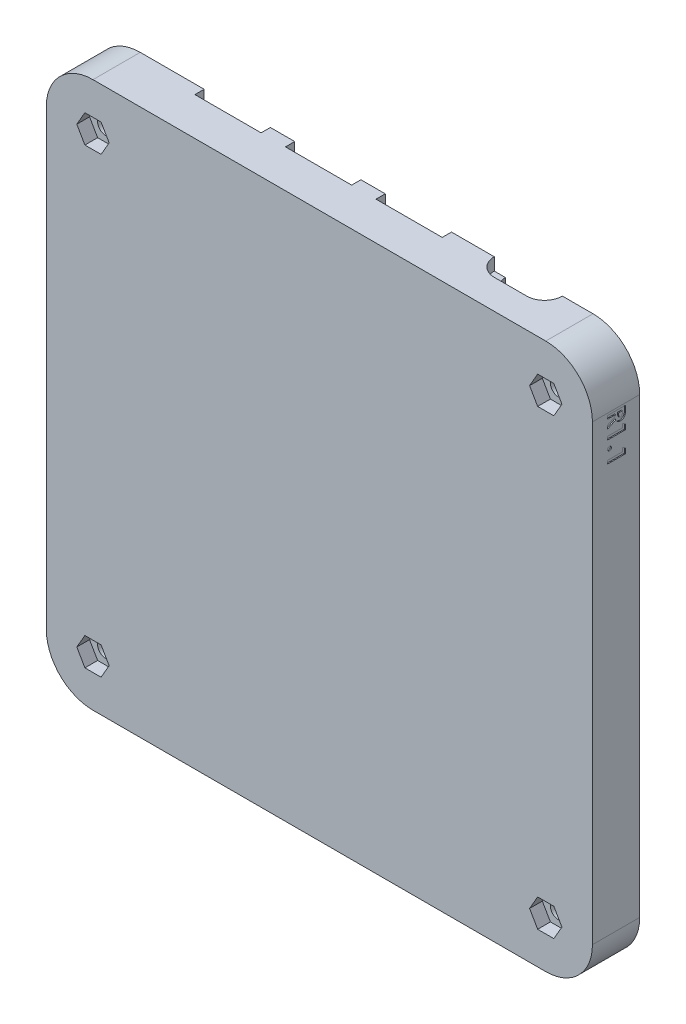
from build123d import *

# Parameters (mm, degrees)
SKETCH1_R             = 3.6
SKETCH1_R_2           = 1.6
BOSS_EXTRUDE1_DEPTH   = 3
BOSS_EXTRUDE1_2_DEPTH = 3
BOSS_EXTRUDE1_3_DEPTH = 3
BOSS_EXTRUDE1_4_DEPTH = 3
BOSS_EXTRUDE2_DEPTH   = 6.28
SKETCH3_R             = 1.6
BOSS_EXTRUDE3_DEPTH   = 3
CUT_EXTRUDE1_REACH    = 109.228
SKETCH5_W             = 13
SKETCH5_H             = 11.3
CUT_EXTRUDE2_START    = -2.436
CUT_EXTRUDE2_DEPTH    = 2.436
CUT_EXTRUDE3_REACH    = 109.228
SKETCH8_W             = 7.93
SKETCH8_H             = 14.6
CUT_EXTRUDE4_REACH    = 109.228
SKETCH9_W             = 10.28
SKETCH9_H             = 1.68
CHAMFER1_SIZE         = 1
CHAMFER1_SIZE2        = 3.732050808
CUT_EXTRUDE5_DEPTH    = 2.5
CUT_EXTRUDE6_DEPTH    = 0.2


with BuildPart() as part:
    # Sketch1 → Boss-Extrude1 (new body)
    with BuildSketch(Plane.XY):
        with Locations((-20.32, -20.32)):
            Circle(SKETCH1_R)
        with Locations((-20.32, -20.32)):
            Circle(SKETCH1_R_2, mode=Mode.SUBTRACT)
    extrude(amount=BOSS_EXTRUDE1_DEPTH)



with BuildPart() as body_2:
    # Sketch1 → Boss-Extrude1 2 (new body)
    with BuildSketch(Plane.XY):
        with Locations((-20.32, -109.22)):
            Circle(SKETCH1_R)
        with Locations((-20.32, -109.22)):
            Circle(SKETCH1_R_2, mode=Mode.SUBTRACT)
    extrude(amount=BOSS_EXTRUDE1_2_DEPTH)


with BuildPart() as body_3:
    # Sketch1 → Boss-Extrude1 3 (new body)
    with BuildSketch(Plane.XY):
        with Locations((-109.22, -109.22)):
            Circle(SKETCH1_R)
        with Locations((-109.22, -109.22)):
            Circle(SKETCH1_R_2, mode=Mode.SUBTRACT)
    extrude(amount=BOSS_EXTRUDE1_3_DEPTH)


with BuildPart() as body_4:
    # Sketch1 → Boss-Extrude1 4 (new body)
    with BuildSketch(Plane.XY):
        with Locations((-109.22, -20.32)):
            Circle(SKETCH1_R)
        with Locations((-109.22, -20.32)):
            Circle(SKETCH1_R_2, mode=Mode.SUBTRACT)
    extrude(amount=BOSS_EXTRUDE1_4_DEPTH)


with BuildPart() as body_5:
    # Sketch2 → Boss-Extrude2 (new body)
    with BuildSketch(Plane.XY.offset(3)):
        with BuildLine():
            Line((-20.32, -11.156), (-109.22, -11.156))
            ThreePointArc((-109.22, -11.156), (-115.699926543, -13.840073457), (-118.384, -20.32))
            Line((-118.384, -20.32), (-118.384, -109.22))
            ThreePointArc((-118.384, -109.22), (-115.699926543, -115.699926543), (-109.22, -118.384))
            Line((-109.22, -118.384), (-20.32, -118.384))
            ThreePointArc((-20.32, -118.384), (-13.840073457, -115.699926543), (-11.156, -109.22))
            Line((-11.156, -109.22), (-11.156, -20.32))
            ThreePointArc((-11.156, -20.32), (-13.840073457, -13.840073457), (-20.32, -11.156))
        make_face()
        with BuildLine():
            Line((-109.22, -114.4), (-20.32, -114.4))
            ThreePointArc((-20.32, -114.4), (-16.657186873, -112.882813127), (-15.14, -109.22))
            Line((-15.14, -109.22), (-15.14, -20.32))
            ThreePointArc((-15.14, -20.32), (-16.657186873, -16.657186873), (-20.32, -15.14))
            Line((-20.32, -15.14), (-109.22, -15.14))
            ThreePointArc((-109.22, -15.14), (-112.882813127, -16.657186873), (-114.4, -20.32))
            Line((-114.4, -20.32), (-114.4, -109.22))
            ThreePointArc((-114.4, -109.22), (-112.882813127, -112.882813127), (-109.22, -114.4))
        make_face(mode=Mode.SUBTRACT)
    extrude(amount=-BOSS_EXTRUDE2_DEPTH)


with BuildPart() as part_1:
    add(part.part)

    add(body_2.part)  # Boss-Extrude3 merges body 2

    add(body_3.part)  # Boss-Extrude3 merges body 3

    add(body_4.part)  # Boss-Extrude3 merges body 4

    add(body_5.part)  # Boss-Extrude3 merges body 5
    # Sketch3 → Boss-Extrude3 (add)
    with BuildSketch(Plane.XY.offset(3)):
        with BuildLine():
            Line((-11.156, -109.22), (-11.156, -20.32))
            ThreePointArc((-11.156, -20.32), (-13.840073457, -13.840073457), (-20.32, -11.156))
            Line((-20.32, -11.156), (-109.22, -11.156))
            ThreePointArc((-109.22, -11.156), (-115.699926543, -13.840073457), (-118.384, -20.32))
            Line((-118.384, -20.32), (-118.384, -109.22))
            ThreePointArc((-118.384, -109.22), (-115.699926543, -115.699926543), (-109.22, -118.384))
            Line((-109.22, -118.384), (-20.32, -118.384))
            ThreePointArc((-20.32, -118.384), (-13.840073457, -115.699926543), (-11.156, -109.22))
        make_face()
        with Locations((-109.22, -109.22)):
            Circle(SKETCH3_R, mode=Mode.SUBTRACT)
        with Locations((-20.32, -109.22)):
            Circle(SKETCH3_R, mode=Mode.SUBTRACT)
        with Locations((-20.32, -20.32)):
            Circle(SKETCH3_R, mode=Mode.SUBTRACT)
        with Locations((-109.22, -20.32)):
            Circle(SKETCH3_R, mode=Mode.SUBTRACT)
    extrude(amount=BOSS_EXTRUDE3_DEPTH)

    # Sketch5 → Cut-Extrude1 (cut, up to next)
    with BuildSketch(Plane(origin=(0, -11.156, 0), x_dir=(1, 0, 0), z_dir=(0, 1, 0)), mode=Mode.PRIVATE) as cut_extrude1_sk1:
        with Locations((-90.17, 7.111)):
            Rectangle(SKETCH5_W, SKETCH5_H)
    cut_extrude1_tool1 = extrude(cut_extrude1_sk1.sketch, amount=-CUT_EXTRUDE1_REACH, mode=Mode.PRIVATE) & part_1.part
    add(cut_extrude1_tool1.solids().sort_by_distance((-90.17, -11.156, -7.111))[0], mode=Mode.SUBTRACT)
    # Sketch5 → Cut-Extrude1 (cut, up to next)
    with BuildSketch(Plane(origin=(0, -11.156, 0), x_dir=(1, 0, 0), z_dir=(0, 1, 0)), mode=Mode.PRIVATE) as cut_extrude1_sk2:
        with Locations((-72.39, 7.111)):
            Rectangle(SKETCH5_W, SKETCH5_H)
    cut_extrude1_tool2 = extrude(cut_extrude1_sk2.sketch, amount=-CUT_EXTRUDE1_REACH, mode=Mode.PRIVATE) & part_1.part
    add(cut_extrude1_tool2.solids().sort_by_distance((-72.39, -11.156, -7.111))[0], mode=Mode.SUBTRACT)
    # Sketch5 → Cut-Extrude1 (cut, up to next)
    with BuildSketch(Plane(origin=(0, -11.156, 0), x_dir=(1, 0, 0), z_dir=(0, 1, 0)), mode=Mode.PRIVATE) as cut_extrude1_sk3:
        with Locations((-54.61, 7.111)):
            Rectangle(SKETCH5_W, SKETCH5_H)
    cut_extrude1_tool3 = extrude(cut_extrude1_sk3.sketch, amount=-CUT_EXTRUDE1_REACH, mode=Mode.PRIVATE) & part_1.part
    add(cut_extrude1_tool3.solids().sort_by_distance((-54.61, -11.156, -7.111))[0], mode=Mode.SUBTRACT)
    # Sketch5 → Cut-Extrude1 (cut, up to next)
    with BuildSketch(Plane(origin=(0, -11.156, 0), x_dir=(1, 0, 0), z_dir=(0, 1, 0)), mode=Mode.PRIVATE) as cut_extrude1_sk4:
        with BuildLine():
            Line((-29.830000144, 1.7), (-33.265, 1.7))
            Line((-33.265, 1.7), (-33.275, 1.7))
            Line((-33.275, 1.7), (-36.210000373, 1.7))
            ThreePointArc((-36.210000373, 1.7), (-37.115096812, 2.074903452), (-37.49, 2.98))
            Line((-37.49, 2.98), (-37.49, 3.579998881))
            ThreePointArc((-37.49, 3.579998881), (-37.115098465, 4.485094895), (-36.210003931, 4.86))
            Line((-36.210003931, 4.86), (-29.830005587, 4.86))
            ThreePointArc((-29.830005587, 4.86), (-28.924905628, 4.485098988), (-28.55, 3.580000941))
            Line((-28.55, 3.580000941), (-28.55, 2.97999964))
            ThreePointArc((-28.55, 2.97999964), (-28.924903498, 2.074903142), (-29.830000144, 1.7))
        make_face()
    cut_extrude1_tool4 = extrude(cut_extrude1_sk4.sketch, amount=-CUT_EXTRUDE1_REACH, mode=Mode.PRIVATE) & part_1.part
    add(cut_extrude1_tool4.solids().sort_by_distance((-33.02, -11.156, -3.28))[0], mode=Mode.SUBTRACT)

    # Sketch7 → Cut-Extrude2 (cut)
    with BuildSketch(Plane(origin=(0, -11.156, 0), x_dir=(1, 0, 0), z_dir=(0, 1, 0)).offset(CUT_EXTRUDE2_START)):
        with BuildLine():
            Line((-36.21, 6.78), (-29.83, 6.78))
            ThreePointArc((-29.83, 6.78), (-26.33, 3.28), (-29.83, -0.22))
            Line((-29.83, -0.22), (-36.21, -0.22))
            ThreePointArc((-36.21, -0.22), (-39.71, 3.28), (-36.21, 6.78))
        make_face()
    extrude(amount=CUT_EXTRUDE2_DEPTH, mode=Mode.SUBTRACT)

    # Sketch8 → Cut-Extrude3 (cut, up to next)
    with BuildSketch(Plane.ZY.offset(118.384), mode=Mode.PRIVATE) as cut_extrude3_sk1:
        with Locations((-5.565, -78.4098)):
            Rectangle(SKETCH8_W, SKETCH8_H)
    cut_extrude3_tool1 = extrude(cut_extrude3_sk1.sketch, amount=-CUT_EXTRUDE3_REACH, mode=Mode.PRIVATE) & part_1.part
    add(cut_extrude3_tool1.solids().sort_by_distance((-118.384, -78.4098, -5.565))[0], mode=Mode.SUBTRACT)
    # Sketch8 → Cut-Extrude3 (cut, up to next)
    with BuildSketch(Plane.ZY.offset(118.384), mode=Mode.PRIVATE) as cut_extrude3_sk2:
        with Locations((-5.565, -58.0898)):
            Rectangle(SKETCH8_W, SKETCH8_H)
    cut_extrude3_tool2 = extrude(cut_extrude3_sk2.sketch, amount=-CUT_EXTRUDE3_REACH, mode=Mode.PRIVATE) & part_1.part
    add(cut_extrude3_tool2.solids().sort_by_distance((-118.384, -58.0898, -5.565))[0], mode=Mode.SUBTRACT)
    # Sketch8 → Cut-Extrude3 (cut, up to next)
    with BuildSketch(Plane.ZY.offset(118.384), mode=Mode.PRIVATE) as cut_extrude3_sk3:
        with Locations((-5.565, -37.7698)):
            Rectangle(SKETCH8_W, SKETCH8_H)
    cut_extrude3_tool3 = extrude(cut_extrude3_sk3.sketch, amount=-CUT_EXTRUDE3_REACH, mode=Mode.PRIVATE) & part_1.part
    add(cut_extrude3_tool3.solids().sort_by_distance((-118.384, -37.7698, -5.565))[0], mode=Mode.SUBTRACT)

    # Sketch9 → Cut-Extrude4 (cut, up to next)
    with BuildSketch(Plane(origin=(0, -118.384, 0), x_dir=(-1, 0, 0), z_dir=(0, -1, 0)), mode=Mode.PRIVATE) as cut_extrude4_sk1:
        with Locations((60.96, 2.44)):
            Rectangle(SKETCH9_W, SKETCH9_H)
    cut_extrude4_tool1 = extrude(cut_extrude4_sk1.sketch, amount=-CUT_EXTRUDE4_REACH, mode=Mode.PRIVATE) & part_1.part
    add(cut_extrude4_tool1.solids().sort_by_distance((-60.96, -118.384, -2.44))[0], mode=Mode.SUBTRACT)
    # Sketch9 → Cut-Extrude4 (cut, up to next)
    with BuildSketch(Plane(origin=(0, -118.384, 0), x_dir=(-1, 0, 0), z_dir=(0, -1, 0)), mode=Mode.PRIVATE) as cut_extrude4_sk2:
        with Locations((73.66, 2.44)):
            Rectangle(SKETCH9_W, SKETCH9_H)
    cut_extrude4_tool2 = extrude(cut_extrude4_sk2.sketch, amount=-CUT_EXTRUDE4_REACH, mode=Mode.PRIVATE) & part_1.part
    add(cut_extrude4_tool2.solids().sort_by_distance((-73.66, -118.384, -2.44))[0], mode=Mode.SUBTRACT)
    # Sketch9 → Cut-Extrude4 (cut, up to next)
    with BuildSketch(Plane(origin=(0, -118.384, 0), x_dir=(-1, 0, 0), z_dir=(0, -1, 0)), mode=Mode.PRIVATE) as cut_extrude4_sk3:
        with Locations((86.36, 2.44)):
            Rectangle(SKETCH9_W, SKETCH9_H)
    cut_extrude4_tool3 = extrude(cut_extrude4_sk3.sketch, amount=-CUT_EXTRUDE4_REACH, mode=Mode.PRIVATE) & part_1.part
    add(cut_extrude4_tool3.solids().sort_by_distance((-86.36, -118.384, -2.44))[0], mode=Mode.SUBTRACT)
    # Sketch9 → Cut-Extrude4 (cut, up to next)
    with BuildSketch(Plane(origin=(0, -118.384, 0), x_dir=(-1, 0, 0), z_dir=(0, -1, 0)), mode=Mode.PRIVATE) as cut_extrude4_sk4:
        with Locations((99.06, 2.44)):
            Rectangle(SKETCH9_W, SKETCH9_H)
    cut_extrude4_tool4 = extrude(cut_extrude4_sk4.sketch, amount=-CUT_EXTRUDE4_REACH, mode=Mode.PRIVATE) & part_1.part
    add(cut_extrude4_tool4.solids().sort_by_distance((-99.06, -118.384, -2.44))[0], mode=Mode.SUBTRACT)

    # Chamfer1
    chamfer1_edges = [part_1.edges().sort_by_distance(p)[0] for p in [
        (-55.82, -118.384, -2.44),
        (-66.1, -118.384, -2.44),
        (-78.8, -118.384, -2.44),
        (-68.52, -118.384, -2.44),
        (-91.5, -118.384, -2.44),
        (-81.22, -118.384, -2.44),
        (-104.2, -118.384, -2.44),
        (-93.92, -118.384, -2.44),
    ]]
    chamfer1_side = [part_1.faces().sort_by_distance(p)[0] for p in [
        (-63.377237599, -118.384, 1.707276714),
    ]]
    chamfer(chamfer1_edges, length=CHAMFER1_SIZE, length2=CHAMFER1_SIZE2, reference=chamfer1_side[0])

    # Sketch10 → Cut-Extrude5 (cut)
    with BuildSketch(Plane.XY.offset(6)):
        Polygon((-23.495426481, -109.22), (-21.90771324, -111.97), (-18.73228676, -111.97), (-17.144573519, -109.22), (-18.73228676, -106.47), (-21.90771324, -106.47), align=None)
        Polygon((-106.044573519, -109.22), (-107.63228676, -106.47), (-110.80771324, -106.47), (-112.395426481, -109.22), (-110.80771324, -111.97), (-107.63228676, -111.97), align=None)
        Polygon((-106.044573519, -20.32), (-107.63228676, -17.57), (-110.80771324, -17.57), (-112.395426481, -20.32), (-110.80771324, -23.07), (-107.63228676, -23.07), align=None)
        Polygon((-23.495426481, -20.32), (-21.90771324, -23.07), (-18.73228676, -23.07), (-17.144573519, -20.32), (-18.73228676, -17.57), (-21.90771324, -17.57), align=None)
    extrude(amount=-CUT_EXTRUDE5_DEPTH, mode=Mode.SUBTRACT)

    # Sketch11 → Cut-Extrude6 (cut)
    with BuildSketch(Plane(origin=(-11.156, 0, 0), x_dir=(0, 0, -1), z_dir=(1, 0, 0))):
        with BuildLine():
            Line((0.5, -20.723846154), (0.5, -21.455817308))
            add(Edge.make_bspline(
                [(0.5, -21.455817308), (0.499828795, -21.504200456), (0.49949952, -21.597254878), (0.49428145, -21.731433032), (0.487053229, -21.854698504), (0.475887663, -21.967444893), (0.461449259, -22.069226116), (0.44393254, -22.160257745), (0.424143413, -22.24059264), (0.39988877, -22.311315783), (0.371956861, -22.374963838), (0.340429771, -22.434126648), (0.304116196, -22.489847087), (0.264487542, -22.543147891), (0.220124454, -22.59307767), (0.171386442, -22.63949808), (0.118624808, -22.683006008), (0.062156822, -22.723659031), (0.002061312, -22.759835578), (-0.060808413, -22.791886214), (-0.126622243, -22.818218821), (-0.195003407, -22.840144621), (-0.266034135, -22.857026153), (-0.339668311, -22.868488089), (-0.415937235, -22.876963141), (-0.467756923, -22.877445998), (-0.494190705, -22.877692308)],
                knots=[0, 0, 0, 0, 0.000145139, 0.000279143, 0.000402781, 0.00051552, 0.000618938, 0.000711065, 0.000793539, 0.000866929, 0.000935057, 0.00100187, 0.001067798, 0.001134404, 0.001200955, 0.001267901, 0.001336126, 0.001405975, 0.001476437, 0.001546359, 0.001617446, 0.001688844, 0.001761629, 0.001836205, 0.001912318, 0.001991573, 0.001991573, 0.001991573, 0.001991573], degree=3))
            add(Edge.make_bspline(
                [(-0.494190705, -22.877692308), (-0.521780964, -22.877048346), (-0.575880432, -22.875785653), (-0.655348139, -22.868984105), (-0.731377283, -22.85655301), (-0.803745259, -22.83772431), (-0.873352771, -22.816083164), (-0.938915518, -22.787305992), (-1.001387014, -22.754828108), (-1.059883576, -22.716255075), (-1.115704531, -22.673923056), (-1.166711169, -22.624691807), (-1.215644906, -22.571750759), (-1.259440697, -22.512123902), (-1.301059855, -22.448439642), (-1.338777897, -22.379432642), (-1.373542965, -22.305553264), (-1.392930369, -22.253612402), (-1.402844551, -22.227051282)],
                knots=[0, 0, 0, 0, 8.278e-05, 0.000162316, 0.000239082, 0.000313563, 0.00038651, 0.000457489, 0.000528056, 0.000597481, 0.00066746, 0.000737887, 0.000809857, 0.000883475, 0.000959513, 0.001037964, 0.001119203, 0.001204224, 0.001204224, 0.001204224, 0.001204224], degree=3))
            Line((-1.402844551, -22.227051282), (-3, -23.03474359))
            Line((-3, -23.03474359), (-3, -22.336426282))
            Line((-3, -22.336426282), (-1.474358974, -21.565192308))
            Line((-1.474358974, -21.565192308), (-1.474358974, -21.352051282))
            Line((-1.474358974, -21.352051282), (-3, -21.352051282))
            Line((-3, -21.352051282), (-3, -20.723846154))
            Line((-3, -20.723846154), (0.5, -20.723846154))
        make_face()
        with BuildLine():
            Line((-0.846153846, -21.352051282), (-0.846153846, -21.596742788))
            add(Edge.make_bspline(
                [(-0.846153846, -21.596742788), (-0.845816922, -21.626658364), (-0.845171784, -21.683940263), (-0.84217926, -21.766319081), (-0.834969123, -21.84113896), (-0.825858432, -21.90872005), (-0.815341805, -21.969406113), (-0.800260708, -22.022644057), (-0.784130369, -22.069291646), (-0.763988461, -22.108679112), (-0.74148554, -22.142468186), (-0.714793749, -22.170790332), (-0.685554308, -22.195741124), (-0.651926871, -22.215312741), (-0.615289149, -22.231125347), (-0.574951838, -22.240931814), (-0.531645292, -22.248712317), (-0.501476463, -22.249221968), (-0.485777244, -22.249487179)],
                knots=[0, 0, 0, 0, 8.9755e-05, 0.000171861, 0.000247208, 0.00031513, 0.000376461, 0.000431743, 0.000480981, 0.000524253, 0.000564118, 0.000602321, 0.000640653, 0.00067901, 0.000718597, 0.000759921, 0.000803261, 0.000850283, 0.000850283, 0.000850283, 0.000850283], degree=3))
            add(Edge.make_bspline(
                [(-0.485777244, -22.249487179), (-0.46722809, -22.24877465), (-0.430791716, -22.247375019), (-0.378336833, -22.233485556), (-0.329783461, -22.211378258), (-0.285364563, -22.181068934), (-0.24638373, -22.142921785), (-0.212301568, -22.099218905), (-0.184723178, -22.04931558), (-0.167060609, -22.002779914), (-0.156204052, -21.960147844), (-0.1484973, -21.921798819), (-0.142521787, -21.877269762), (-0.13673705, -21.826809142), (-0.132755271, -21.770199956), (-0.129937957, -21.707546753), (-0.128768959, -21.638814125), (-0.128398483, -21.590900196), (-0.128205128, -21.565893429)],
                knots=[0, 0, 0, 0, 5.5548e-05, 0.000109114, 0.000161511, 0.00021499, 0.000269533, 0.000324507, 0.000380689, 0.000439937, 0.000473268, 0.000512593, 0.000557212, 0.000608004, 0.00066495, 0.000727413, 0.000796137, 0.000871161, 0.000871161, 0.000871161, 0.000871161], degree=3))
            Line((-0.128205128, -21.565893429), (-0.128205128, -21.352051282))
            Line((-0.128205128, -21.352051282), (-0.846153846, -21.352051282))
        make_face(mode=Mode.SUBTRACT)
        Polygon((0.5, -23.925869391), (0.5, -24.896923077), (-3, -24.896923077), (-3, -24.268717949), (-0.083333333, -24.268717949), (-0.083333333, -23.550769231), align=None)
        with BuildLine():
            add(Edge.make_bspline(
                [(-2.282051282, -26.53474359), (-2.283430942, -26.560109529), (-2.286147254, -26.610050683), (-2.306788367, -26.682304112), (-2.343072828, -26.747893229), (-2.391248119, -26.806124142), (-2.448581695, -26.855567299), (-2.514686244, -26.89014188), (-2.586310262, -26.912506459), (-2.636414869, -26.914919043), (-2.662059295, -26.916153846)],
                knots=[0, 0, 0, 0, 7.6045e-05, 0.00014972, 0.000223133, 0.00029935, 0.000375475, 0.000448557, 0.000521756, 0.0005985, 0.0005985, 0.0005985, 0.0005985], degree=3))
            add(Edge.make_bspline(
                [(-2.662059295, -26.916153846), (-2.687707677, -26.914927136), (-2.737820017, -26.912530364), (-2.809586944, -26.889989001), (-2.876227844, -26.855622377), (-2.934179886, -26.806120014), (-2.983259201, -26.748135559), (-3.019200801, -26.682153579), (-3.041003097, -26.610188041), (-3.043569822, -26.560133689), (-3.044871795, -26.53474359)],
                knots=[0, 0, 0, 0, 7.6743e-05, 0.000149942, 0.000223644, 0.000300307, 0.00037697, 0.000450384, 0.000524255, 0.0006003, 0.0006003, 0.0006003, 0.0006003], degree=3))
            add(Edge.make_bspline(
                [(-3.044871795, -26.53474359), (-3.043559148, -26.509359505), (-3.04097138, -26.459317011), (-3.019382772, -26.387463165), (-2.983016405, -26.321964745), (-2.934239053, -26.263994855), (-2.876021692, -26.214712663), (-2.809795899, -26.179340372), (-2.737792871, -26.157007037), (-2.687698487, -26.154577046), (-2.662059295, -26.153333333)],
                knots=[0, 0, 0, 0, 7.6045e-05, 0.000149916, 0.000222715, 0.000299378, 0.000376041, 0.000450072, 0.000523271, 0.000600014, 0.000600014, 0.000600014, 0.000600014], degree=3))
            add(Edge.make_bspline(
                [(-2.662059295, -26.153333333), (-2.63642422, -26.154585247), (-2.58633788, -26.157031262), (-2.514474883, -26.179187056), (-2.448788968, -26.214765829), (-2.391188829, -26.263990905), (-2.343313729, -26.322205833), (-2.30660889, -26.387313471), (-2.286179205, -26.459454438), (-2.283441704, -26.509383694), (-2.282051282, -26.53474359)],
                knots=[0, 0, 0, 0, 7.6743e-05, 0.000149942, 0.000223356, 0.000299482, 0.000375698, 0.000448497, 0.000522171, 0.000598216, 0.000598216, 0.000598216, 0.000598216], degree=3))
        make_face()
        Polygon((0.5, -28.009202724), (0.5, -28.98025641), (-3, -28.98025641), (-3, -28.352051282), (-0.083333333, -28.352051282), (-0.083333333, -27.634102564), align=None)
    extrude(amount=-CUT_EXTRUDE6_DEPTH, mode=Mode.SUBTRACT)


solid = part_1.part
